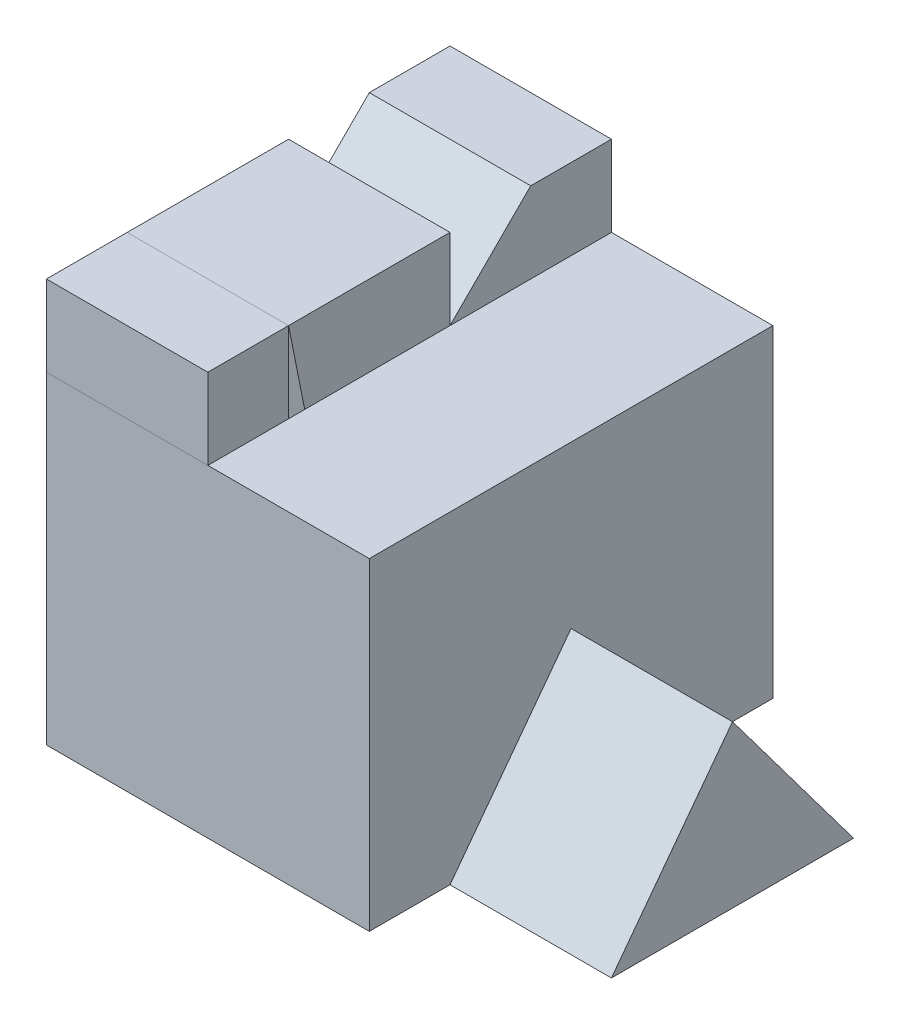
from build123d import *

# Parameters (mm, degrees)
BOSS_EXTRUDE1_DEPTH = 2
SKETCH2_W           = 5
SKETCH2_H           = 4
BOSS_EXTRUDE2_DEPTH = 2
SKETCH3_W           = 1
SKETCH3_H           = 4
BOSS_EXTRUDE3_DEPTH = 2
SKETCH5_W           = 2
SKETCH5_H           = 1
BOSS_EXTRUDE8_DEPTH = 1


with BuildPart() as part:
    # Sketch1 → Boss-Extrude1 (new body)
    with BuildSketch(Plane(origin=(0, 0, 0), x_dir=(0, 0, -1), z_dir=(1, 0, 0))):
        Polygon((-1.5, 0), (0, 2), (1.5, 0), align=None)
    extrude(amount=BOSS_EXTRUDE1_DEPTH)

    # Sketch2 → Boss-Extrude2 (add)
    with BuildSketch(Plane.ZY):
        with Locations((0, 2)):
            Rectangle(SKETCH2_W, SKETCH2_H)
    extrude(amount=BOSS_EXTRUDE2_DEPTH)

    # Sketch3 → Boss-Extrude3 (add)
    with BuildSketch(Plane.ZY.offset(2)):
        Polygon((-2.5, 0), (0.5, 0), (1.3, 4), (-0.5, 4), (-2.5, 4), align=None)
        Polygon((-2.5, 4), (-0.5, 4), (-1.5, 5), (-2.5, 5), align=None)
        Polygon((1.3, 4), (1.5, 5), (-0.5, 5), (-0.5, 4), align=None)
        with Locations((2, 2)):
            Rectangle(SKETCH3_W, SKETCH3_H)
    extrude(amount=BOSS_EXTRUDE3_DEPTH)


with BuildPart() as body_2:
    # Sketch5 → Boss-Extrude8 (new body)
    with BuildSketch(Plane(origin=(0, 4, 0), x_dir=(1, 0, 0), z_dir=(0, 1, 0))):
        with Locations((-3, -2)):
            Rectangle(SKETCH5_W, SKETCH5_H)
    extrude(amount=BOSS_EXTRUDE8_DEPTH)


solid = Compound([part.part, body_2.part])
